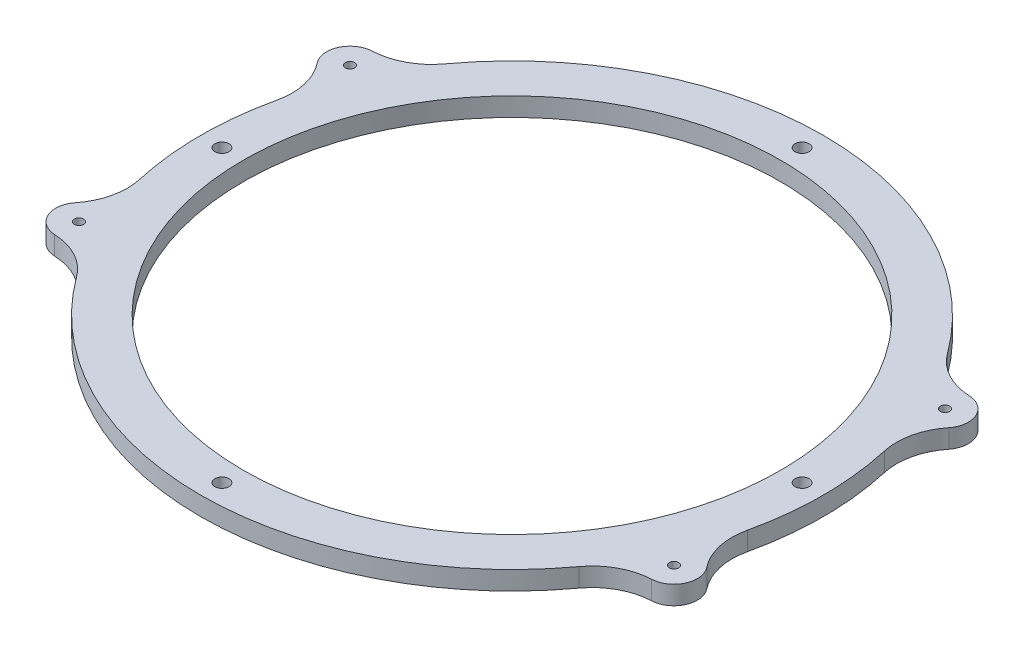
from build123d import *

# Parameters (mm, degrees)
SKETCH1_R           = 86.25
BOSS_EXTRUDE1_DEPTH = 6
SKETCH2_R           = 1.5
CUT_EXTRUDE1_DEPTH  = 6
SKETCH3_R           = 2.25
CUT_EXTRUDE2_DEPTH  = 6
CUT_EXTRUDE3_DEPTH  = 6
FILLET1_R           = 20


with BuildPart() as part:
    # Sketch1 → Boss-Extrude1 (new body)
    with BuildSketch(Plane(origin=(0, 0, 0), x_dir=(1, 0, 0), z_dir=(0, 1, 0))):
        with BuildLine():
            Line((75.993420768, 65), (110, 65))
            Line((110, 65), (110, -65))
            Line((110, -65), (75.993420768, -65))
            ThreePointArc((75.993420768, -65), (0, -100), (-75.993420768, -65))
            Line((-75.993420768, -65), (-110, -65))
            Line((-110, -65), (-110, 65))
            Line((-110, 65), (-75.993420768, 65))
            ThreePointArc((-75.993420768, 65), (0, 100), (75.993420768, 65))
        make_face()
        Circle(SKETCH1_R, mode=Mode.SUBTRACT)
    extrude(amount=BOSS_EXTRUDE1_DEPTH)

    # Sketch2 → Cut-Extrude1 (cut)
    with BuildSketch(Plane(origin=(0, 0, 0), x_dir=(1, 0, 0), z_dir=(0, 1, 0))):
        with Locations((-95.5, 43.5)):
            Circle(SKETCH2_R)
        with Locations((95.5, 43.5)):
            Circle(SKETCH2_R)
        with Locations((95.5, -43.5)):
            Circle(SKETCH2_R)
        with Locations((-95.5, -43.5)):
            Circle(SKETCH2_R)
    extrude(amount=CUT_EXTRUDE1_DEPTH, mode=Mode.SUBTRACT)

    # Sketch3 → Cut-Extrude2 (cut)
    with BuildSketch(Plane(origin=(0, 0, 0), x_dir=(1, 0, 0), z_dir=(0, 1, 0))):
        with Locations((0, 93.125)):
            Circle(SKETCH3_R)
        with Locations((93.125, 0)):
            Circle(SKETCH3_R)
        with Locations((0, -93.125)):
            Circle(SKETCH3_R)
        with Locations((-93.125, 0)):
            Circle(SKETCH3_R)
    extrude(amount=CUT_EXTRUDE2_DEPTH, mode=Mode.SUBTRACT)

    # Sketch4 → Cut-Extrude3 (cut)
    with BuildSketch(Plane(origin=(0, 0, 0), x_dir=(1, 0, 0), z_dir=(0, 1, 0))):
        with BuildLine():
            Line((98.608905775, -36.674701114), (93.856581268, -34.510029742))
            ThreePointArc((93.856581268, -34.510029742), (100, 0), (93.856581268, 34.510029742))
            Line((93.856581268, 34.510029742), (98.608905775, 36.674701114))
            ThreePointArc((98.608905775, 36.674701114), (102.325298886, 46.608905775), (92.391094225, 50.325298886))
            Line((92.391094225, 50.325298886), (87.638769717, 48.160627513))
            ThreePointArc((87.638769717, 48.160627513), (82.248188777, 56.879130117), (75.993420768, 65))
            Line((75.993420768, 65), (110, 65))
            Line((110, 65), (110, -65))
            Line((110, -65), (75.993420768, -65))
            ThreePointArc((75.993420768, -65), (82.248188777, -56.879130117), (87.638769717, -48.160627513))
            Line((87.638769717, -48.160627513), (92.391094225, -50.325298886))
            ThreePointArc((92.391094225, -50.325298886), (102.325298886, -46.608905775), (98.608905775, -36.674701114))
        make_face()
        with BuildLine():
            Line((-98.608905775, 36.674701114), (-93.856581268, 34.510029742))
            ThreePointArc((-93.856581268, 34.510029742), (-100, 0), (-93.856581268, -34.510029742))
            Line((-93.856581268, -34.510029742), (-98.608905775, -36.674701114))
            ThreePointArc((-98.608905775, -36.674701114), (-102.325298886, -46.608905775), (-92.391094225, -50.325298886))
            Line((-92.391094225, -50.325298886), (-87.638769717, -48.160627513))
            ThreePointArc((-87.638769717, -48.160627513), (-82.248188777, -56.879130117), (-75.993420768, -65))
            Line((-75.993420768, -65), (-110, -65))
            Line((-110, -65), (-110, 65))
            Line((-110, 65), (-75.993420768, 65))
            ThreePointArc((-75.993420768, 65), (-82.248188777, 56.879130117), (-87.638769717, 48.160627513))
            Line((-87.638769717, 48.160627513), (-92.391094225, 50.325298886))
            ThreePointArc((-92.391094225, 50.325298886), (-102.325298886, 46.608905775), (-98.608905775, 36.674701114))
        make_face()
    extrude(amount=CUT_EXTRUDE3_DEPTH, mode=Mode.SUBTRACT)

    # Fillet1
    fillet1_edges = [part.edges().sort_by_distance(p)[0] for p in [
        (87.638769717, 3, -48.160627513),
        (93.856581268, 3, -34.510029742),
        (93.856581268, 3, 34.510029742),
        (87.638769717, 3, 48.160627513),
        (-87.638769717, 3, 48.160627513),
        (-93.856581268, 3, 34.510029742),
        (-93.856581268, 3, -34.510029742),
        (-87.638769717, 3, -48.160627513),
    ]]
    fillet(fillet1_edges, radius=FILLET1_R)


solid = part.part
